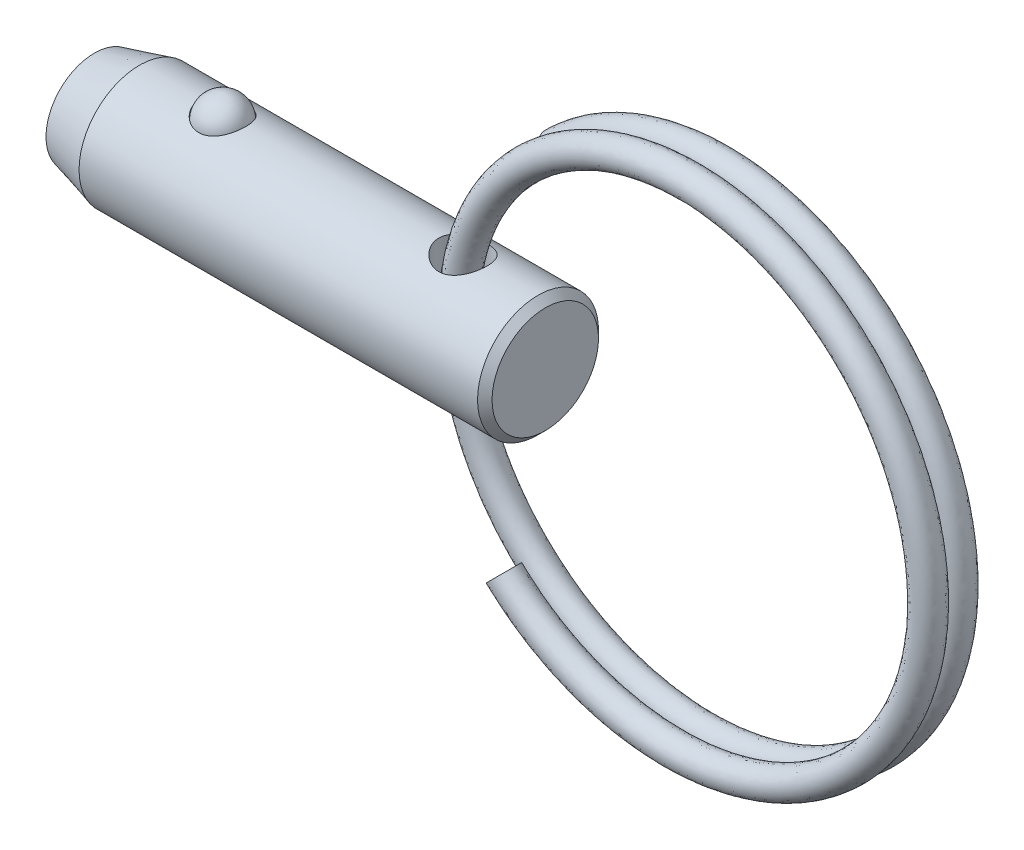
from build123d import *

# Parameters (mm, degrees)
SKETCH4_W          = 1.27
SKETCH4_H          = 6.35
SWEEP1_PITCH       = 1.5494
SWEEP1_HEIGHT      = 1.355725
SWEEP1_RADIUS      = 13.462
SKETCH6_R          = 0.762
SWEEP2_PITCH       = 1.5494
SWEEP2_HEIGHT      = 1.355725
SWEEP2_RADIUS      = 13.462
SWEEP2_START_ANGLE = -180
SKETCH6_2_R        = 0.762


with BuildPart() as part:
    # Sketch1 → Revolve1 (revolve)
    with BuildSketch(Plane.XY):
        Polygon((11.8364, 2.794), (11.4554, 3.175), (-9.466547737, 3.175), (-11.8364, 2.54), (-11.8364, 0), (11.8364, 0), align=None)
    revolve(axis=Axis((11.8364, 0, 0), (1, 0, 0)))

    # Sketch2 → Cut-Revolve1 (revolve, cut)
    with BuildSketch(Plane.XY):
        with BuildLine():
            Line((-3.844582051, 2.8575), (-6.359182051, 2.8575))
            ThreePointArc((-6.359182051, 2.8575), (-5.101882051, 4.1148), (-3.844582051, 2.8575))
        make_face()
    revolve(axis=Axis((-3.844582051, 2.8575, 0), (1, 0, 0)), mode=Mode.SUBTRACT)

    # Sketch4 → Cut-Revolve2 (revolve, cut)
    with BuildSketch(Plane.XY):
        with Locations((8.1534, 0)):
            Rectangle(SKETCH4_W, SKETCH4_H)
    revolve(axis=Axis((7.5184, -3.175, 0), (0, 1, 0)), mode=Mode.SUBTRACT)


with BuildPart() as body_2:
    # Sketch3 → Revolve2 (revolve)
    with BuildSketch(Plane.XY):
        with BuildLine():
            Line((-3.869982051, 2.8575), (-6.333782051, 2.8575))
            ThreePointArc((-6.333782051, 2.8575), (-5.101882051, 4.0894), (-3.869982051, 2.8575))
        make_face()
    revolve(axis=Axis((-3.869982051, 2.8575, 0), (1, 0, 0)))


with BuildPart() as body_3:
    # Sweep1: sweep along a helix
    with BuildLine() as sweep1_path:
        Helix(SWEEP1_PITCH, SWEEP1_HEIGHT, SWEEP1_RADIUS, center=(20.003425091, 0, 0), direction=(0, 0, -1), lefthand=True)
    # Sketch6 → Sweep1 (sweep)
    with BuildSketch(Plane(origin=(114.003847968, 0, 0), x_dir=(0, 0, -1), z_dir=(0, 1, 0))):
        with Locations((0, 106.700422877)):
            Circle(SKETCH6_R)
    sweep(path=sweep1_path.line, is_frenet=True)

    # Sweep2: sweep along a helix
    with BuildLine() as sweep2_path:
        add(Helix(SWEEP2_PITCH, SWEEP2_HEIGHT, SWEEP2_RADIUS, center=(20.003425091, 0, 0), direction=(0, 0, 1), lefthand=True, mode=Mode.PRIVATE).rotate(Axis((20.003425091, 0, 0), (0, 0, 1)), SWEEP2_START_ANGLE))
    # Sketch6_2 → Sweep2 (sweep)
    with BuildSketch(Plane(origin=(114.003847968, 0, 0), x_dir=(0, 0, -1), z_dir=(0, 1, 0))):
        with Locations((0, 106.700422877)):
            Circle(SKETCH6_2_R)
    sweep(path=sweep2_path.line, is_frenet=True)


solid = Compound([part.part, body_2.part, body_3.part])
